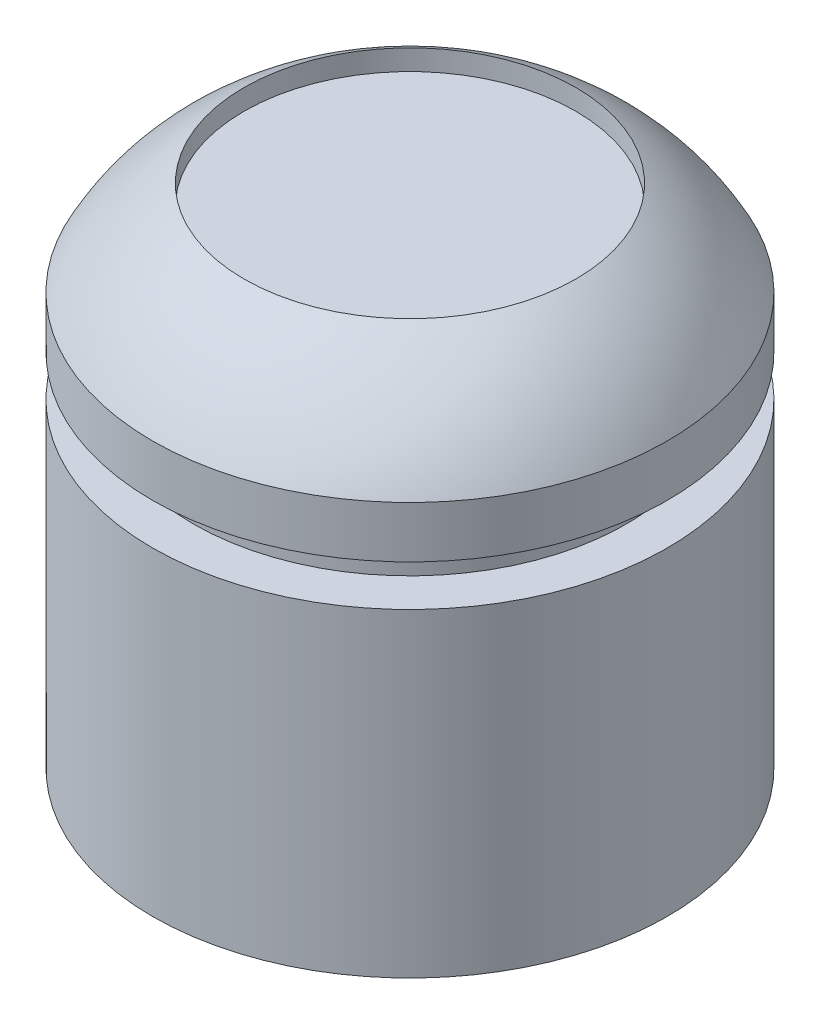
from build123d import *

# Parameters (mm, degrees)
SKETCH2_R          = 1.5
CUT_EXTRUDE1_DEPTH = 4
SKETCH3_R          = 8.057142585
CUT_EXTRUDE2_DEPTH = 1


with BuildPart() as part:
    # Sketch1 → Revolve2 (revolve)
    with BuildSketch(Plane(origin=(0, 0, 0), x_dir=(0, 0, -1), z_dir=(1, 0, 0))):
        with BuildLine():
            Line((0, 0), (0, 15.5))
            Line((0, 15.5), (2, 15.5))
            Line((2, 15.5), (2, 17.5))
            Line((2, 17.5), (0, 17.5))
            Line((0, 17.5), (0, 20))
            add(Edge.make_bspline(
                [(0, 20), (1.556141404, 22.961218059), (4.442857415, 24.588216471)],
                knots=[0, 0, 0, 1, 1, 1], degree=2))
            Line((4.442857415, 24.588216471), (12.5, 24.588216471))
            Line((12.5, 24.588216471), (12.5, 0))
            Line((12.5, 0), (0, 0))
        make_face()
    revolve(axis=Axis((0, 24.588216471, -12.5), (0, -1, 0)))

    # Sketch2 → Cut-Extrude1 (cut)
    with BuildSketch(Plane.XZ):
        with Locations((0, -12.5)):
            Circle(SKETCH2_R)
    extrude(amount=-CUT_EXTRUDE1_DEPTH, mode=Mode.SUBTRACT)

    # Sketch3 → Cut-Extrude2 (cut)
    with BuildSketch(Plane(origin=(0, 24.588216471, 0), x_dir=(1, 0, 0), z_dir=(0, 1, 0))):
        with Locations((0, 12.5)):
            Circle(SKETCH3_R)
    extrude(amount=-CUT_EXTRUDE2_DEPTH, mode=Mode.SUBTRACT)


solid = part.part
